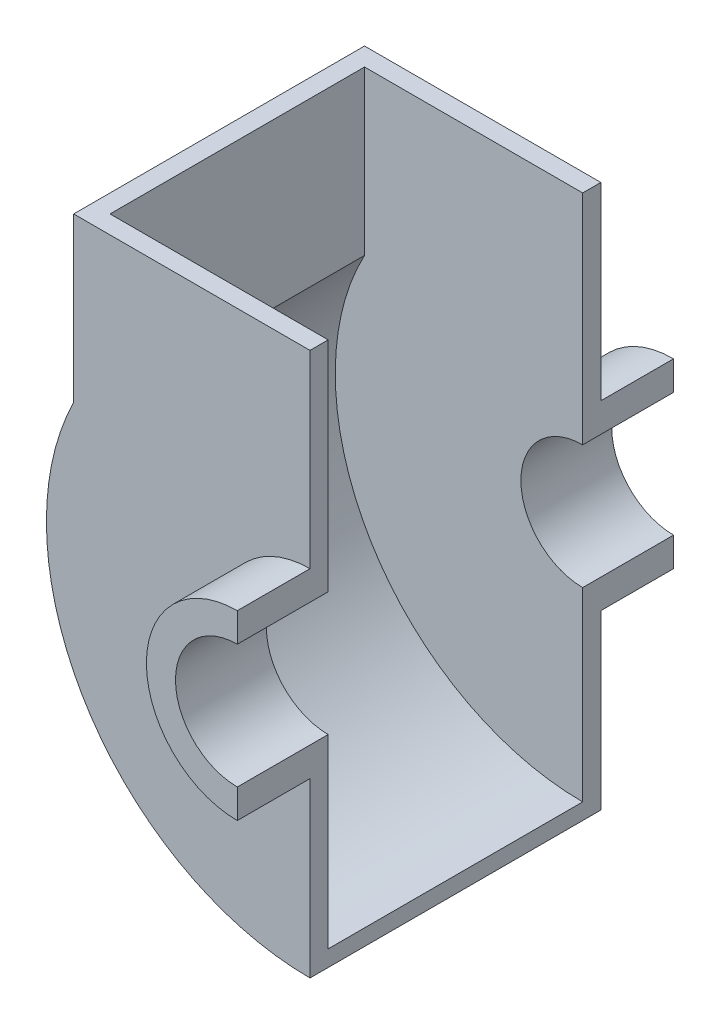
from build123d import *

# Parameters (mm, degrees)
BOSS_EXTRUDE1_DEPTH      = 20
BOSS_EXTRUDE1_DEPTH_BACK = 5
BOSS_EXTRUDE3_DEPTH      = 5
BOSS_EXTRUDE4_DEPTH      = 75


with BuildPart() as part:
    # Sketch1 → Boss-Extrude1 (new body, two sides)
    with BuildSketch(Plane.XY) as boss_extrude1_sk:
        with BuildLine():
            Line((0, 25), (0, 17))
            ThreePointArc((0, 17), (-17, 0), (0, -17))
            Line((0, -17), (0, -25))
            ThreePointArc((0, -25), (-25, 0), (0, 25))
        make_face()
    extrude(amount=BOSS_EXTRUDE1_DEPTH)
    extrude(boss_extrude1_sk.sketch, amount=-BOSS_EXTRUDE1_DEPTH_BACK)

    # Sketch2 → Boss-Extrude3 (add)
    with BuildSketch(Plane.XY):
        with BuildLine():
            Line((0, 25), (0, 77))
            Line((0, 77), (-65, 77))
            Line((-65, 77), (-65, 32.113081447))
            ThreePointArc((-65, 32.113081447), (-61.581037686, -38.262590053), (0, -72.5))
            Line((0, -72.5), (0, -25))
            ThreePointArc((0, -25), (-25, 0), (0, 25))
        make_face()
    extrude(amount=-BOSS_EXTRUDE3_DEPTH)


with BuildPart() as body_2:
    # Mirror7: mirrored copy
    add(part.part.mirror(Plane.XY.offset(-40)))


with BuildPart() as part_1:
    add(part.part)

    add(body_2.part)  # Boss-Extrude4 merges body 2
    # Sketch3 → Boss-Extrude4 (add)
    with BuildSketch(Plane.XY):
        with BuildLine():
            Line((-65, 32.113081447), (-65, 77))
            Line((-65, 77), (-60, 77))
            Line((-60, 77), (-60, 32.113081447))
            ThreePointArc((-60, 32.113081447), (-58.380864924, -34.970339014), (0, -68.053287944))
            Line((0, -68.053287944), (0, -72.5))
            ThreePointArc((0, -72.5), (-61.581037686, -38.262590053), (-65, 32.113081447))
        make_face()
    extrude(amount=-BOSS_EXTRUDE4_DEPTH)


solid = part_1.part
